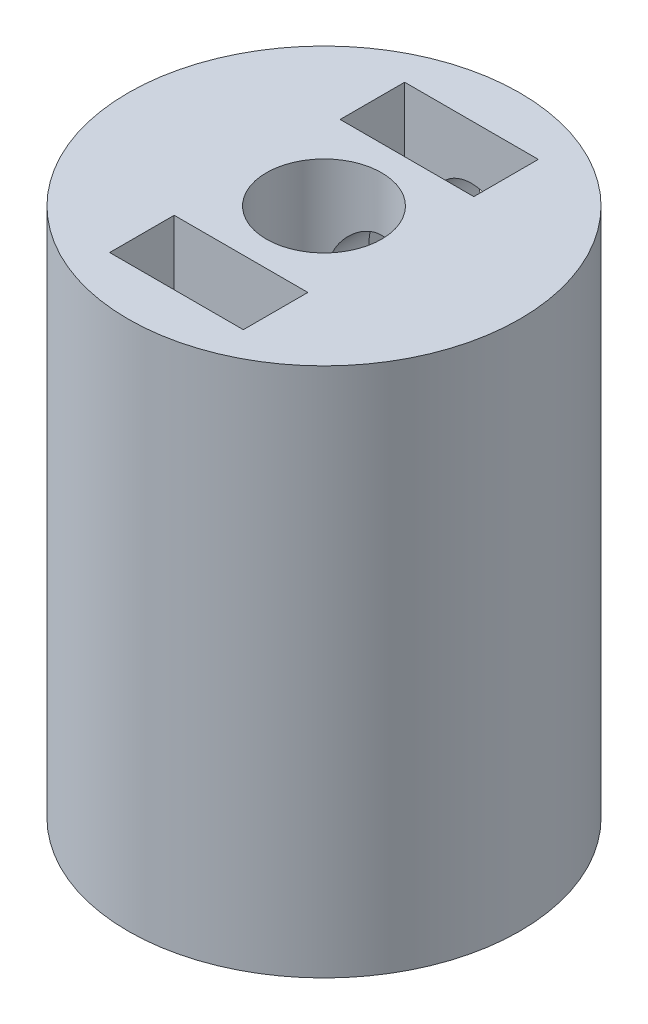
from build123d import *

# Parameters (mm, degrees)
SKETCH1_R           = 8.5
SKETCH1_R_2         = 2.5
BOSS_EXTRUDE1_DEPTH = 23
SKETCH3_W           = 5.8
SKETCH3_H           = 2.8
CUT_EXTRUDE2_DEPTH  = 8
SKETCH7_W           = 5.8
SKETCH7_H           = 2.8
CUT_EXTRUDE5_DEPTH  = 8
SKETCH4_R           = 1.65
CUT_EXTRUDE3_DEPTH  = 9.5


with BuildPart() as part:
    # Sketch1 → Boss-Extrude1 (new body)
    with BuildSketch(Plane(origin=(0, 0, 0), x_dir=(1, 0, 0), z_dir=(0, 1, 0))):
        Circle(SKETCH1_R)
        Circle(SKETCH1_R_2, mode=Mode.SUBTRACT)
    extrude(amount=BOSS_EXTRUDE1_DEPTH)

    # Sketch3 → Cut-Extrude2 (cut)
    with BuildSketch(Plane(origin=(0, 23, 0), x_dir=(1, 0, 0), z_dir=(0, 1, 0))):
        with Locations((0, 5)):
            Rectangle(SKETCH3_W, SKETCH3_H)
    cut_extrude2 = extrude(amount=-CUT_EXTRUDE2_DEPTH, mode=Mode.SUBTRACT)

    # Sketch7 → Cut-Extrude5 (cut)
    with BuildSketch(Plane.XZ):
        with Locations((0, -5.5)):
            Rectangle(SKETCH7_W, SKETCH7_H)
    extrude(amount=-CUT_EXTRUDE5_DEPTH, mode=Mode.SUBTRACT)

    # Sketch4 → Cut-Extrude3 (cut, through all)
    with BuildSketch(Plane.XY):
        with Locations((0, 19)):
            Circle(SKETCH4_R)
        with Locations((0, 4)):
            Circle(SKETCH4_R)
    extrude(amount=-CUT_EXTRUDE3_DEPTH, mode=Mode.SUBTRACT)

    # Mirror1: Cut-Extrude2 across plane
    add(cut_extrude2.mirror(Plane.XY), mode=Mode.SUBTRACT)


solid = part.part
